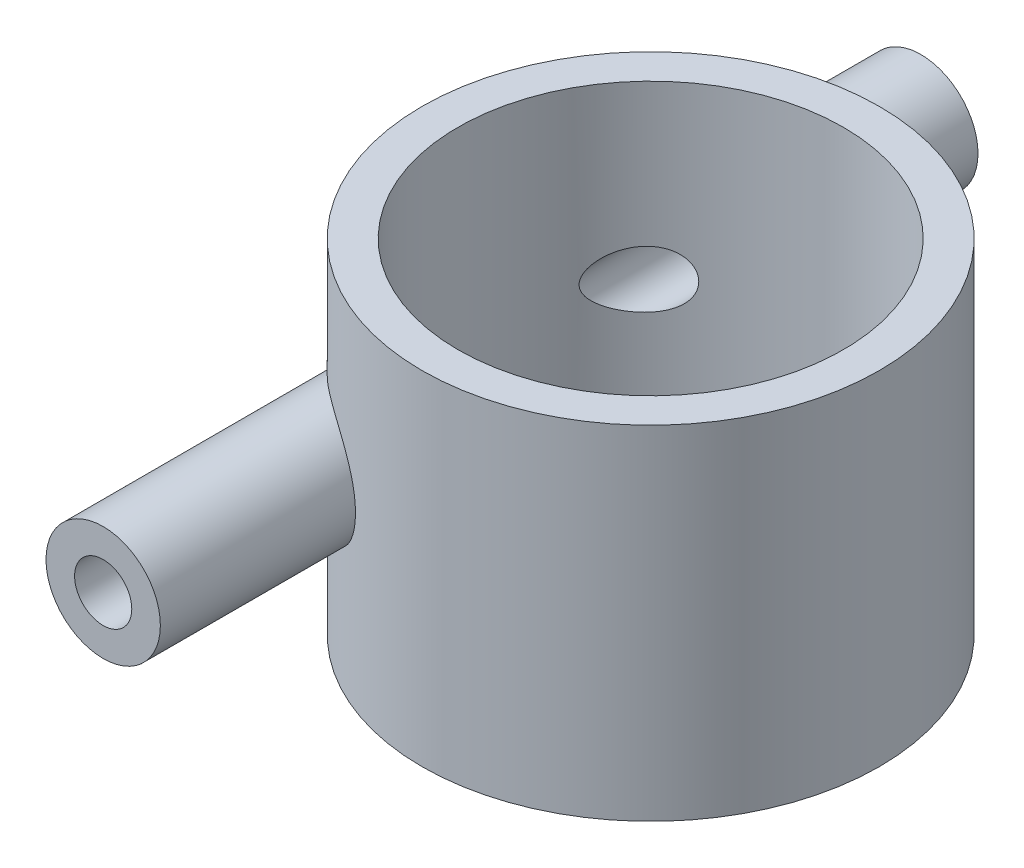
from build123d import *

# Parameters (mm, degrees)
SKETCH1_R                       = 12.7
BOSS_EXTRUDE1_DEPTH             = 19.05
SKETCH2_R                       = 10.7
CUT_EXTRUDE1_DEPTH              = 17.05
BOSS_EXTRUDE2_REACH             = 36.196
SKETCH3_R                       = 3.175
SKETCH3_R_2                     = 1.5875
BOSS_EXTRUDE2_DIRECTION_2_DEPTH = 10
CUT_EXTRUDE2_REACH              = 44.159
SKETCH4_R                       = 1.5875
CUT_EXTRUDE2_DIRECTION_2_DEPTH  = 43.158658819


with BuildPart() as part:
    # Sketch1 → Boss-Extrude1 (new body)
    with BuildSketch(Plane(origin=(0, 0, 0), x_dir=(1, 0, 0), z_dir=(0, 1, 0))):
        with Locations(Location((0, 0, 0), (0, 0, 90))):
            Circle(SKETCH1_R)
    extrude(amount=BOSS_EXTRUDE1_DEPTH)

    # Sketch2 → Cut-Extrude1 (cut)
    with BuildSketch(Plane(origin=(0, 19.05, 0), x_dir=(1, 0, 0), z_dir=(0, 1, 0))):
        with Locations(Location((0, 0, 0), (0, 0, 270))):
            Circle(SKETCH2_R)
    extrude(amount=-CUT_EXTRUDE1_DEPTH, mode=Mode.SUBTRACT)

    # Sketch3 → Boss-Extrude2 (add, up to next)
    with BuildSketch(Plane.XY.offset(12.7), mode=Mode.PRIVATE) as boss_extrude2_sk1:
        with Locations(Location((-7.7, 9.525, 0), (0, 0, 180))):
            Circle(SKETCH3_R)
        with Locations((-7.7, 9.525)):
            Circle(SKETCH3_R_2, mode=Mode.SUBTRACT)
    boss_extrude2_tool1 = extrude(boss_extrude2_sk1.sketch, amount=-BOSS_EXTRUDE2_REACH, mode=Mode.PRIVATE) - part.part
    boss_extrude2 = boss_extrude2_tool1.solids().sort_by_distance((-4.614803, 9.525, 12.7))[0]
    add(boss_extrude2)

    # Sketch3 → Boss-Extrude2 direction 2 (add)
    with BuildSketch(Plane.XY.offset(12.7)):
        with Locations(Location((-7.7, 9.525, 0), (0, 0, 180))):
            Circle(SKETCH3_R)
        with Locations((-7.7, 9.525)):
            Circle(SKETCH3_R_2, mode=Mode.SUBTRACT)
    boss_extrude2_direction_2 = extrude(amount=BOSS_EXTRUDE2_DIRECTION_2_DEPTH)

    # Sketch4 → Cut-Extrude2 (cut, up to next)
    with BuildSketch(Plane.XY.offset(22.7), mode=Mode.PRIVATE) as cut_extrude2_sk1:
        with Locations((-7.7, 9.525)):
            Circle(SKETCH4_R)
    cut_extrude2_tool1 = extrude(cut_extrude2_sk1.sketch, amount=-CUT_EXTRUDE2_REACH, mode=Mode.PRIVATE) & part.part
    cut_extrude2 = cut_extrude2_tool1.solids().sort_by_distance((-7.7, 9.525, 22.7))[0]
    add(cut_extrude2, mode=Mode.SUBTRACT)

    # Sketch4 → Cut-Extrude2 direction 2 (cut)
    with BuildSketch(Plane.XY.offset(22.7)):
        with Locations((-7.7, 9.525)):
            Circle(SKETCH4_R)
    cut_extrude2_direction_2 = extrude(amount=CUT_EXTRUDE2_DIRECTION_2_DEPTH, mode=Mode.SUBTRACT)

    # Mirror1: Boss-Extrude2, Boss-Extrude2 direction 2, Cut-Extrude2, Cut-Extrude2 direction 2 across plane
    add(boss_extrude2.mirror(Plane.XY))
    add(boss_extrude2_direction_2.mirror(Plane.XY))
    add(cut_extrude2.mirror(Plane.XY), mode=Mode.SUBTRACT)
    add(cut_extrude2_direction_2.mirror(Plane.XY), mode=Mode.SUBTRACT)


solid = part.part
